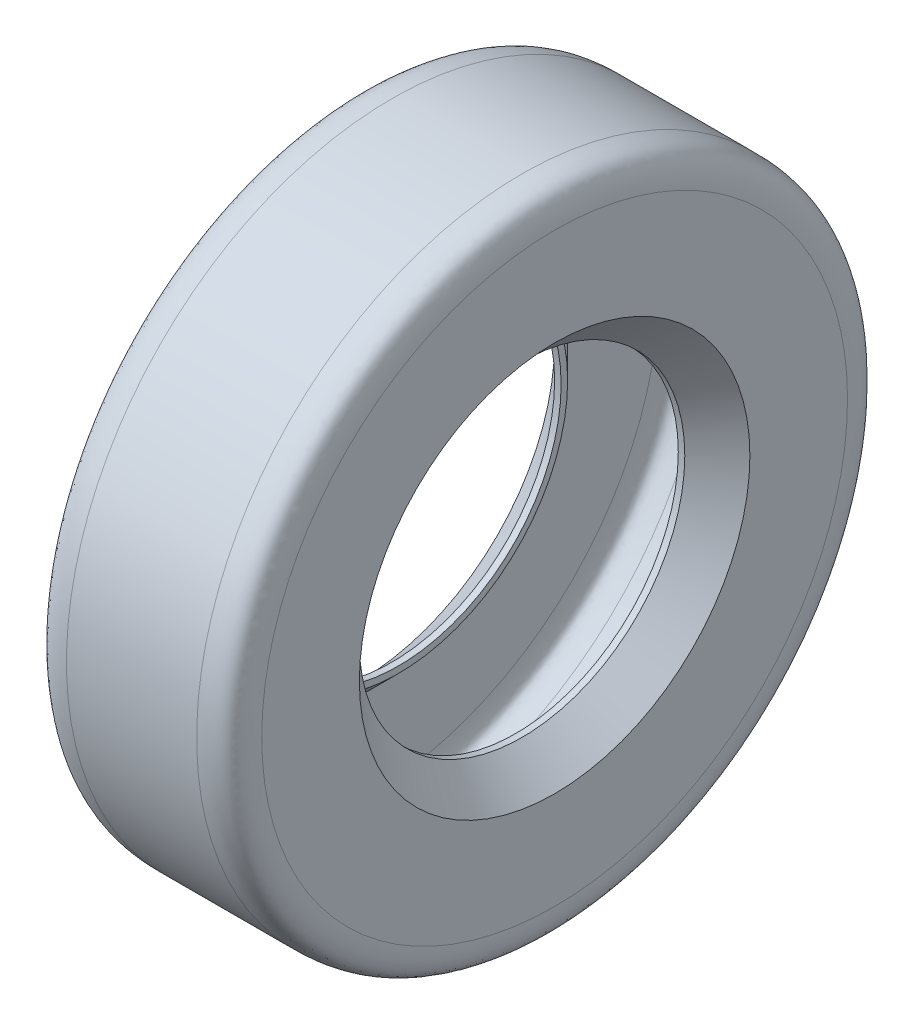
from build123d import *


with BuildPart() as part:
    # Sketch2 → Revolve4 (revolve)
    with BuildSketch(Plane.XY):
        with BuildLine():
            Line((-25.4, 127), (25.4, 127))
            add(Edge.make_bspline(
                [(38.1, 114.3), (38.1, 116.276431222), (38.064423316, 127.022398823), (28.686368964, 127), (25.4, 127)],
                knots=[0, 0, 0, 0, 0.479280716, 1, 1, 1, 1], degree=3))
            Line((38.1, 114.3), (38.1, 76.2))
            Line((38.1, 76.2), (25.4, 63.5))
            Line((25.4, 63.5), (22.86, 63.5))
            Line((22.86, 63.5), (22.86, 66.04))
            Line((22.86, 66.04), (35.56, 78.74))
            Line((35.56, 78.74), (35.56, 114.3))
            add(Edge.make_bspline(
                [(35.56, 114.3), (35.56, 114.437804617), (35.559848134, 114.69919797), (35.554529075, 115.335705853), (35.530423845, 116.249768154), (35.448501321, 117.490904626), (35.291134285, 118.78768894), (35.040001719, 120.054632818), (34.691360923, 121.193385659), (34.249332566, 122.117984468), (33.807571329, 122.705830521), (33.23403142, 123.186604386), (32.200420459, 123.75056219), (30.417055007, 124.242459368), (28.301224859, 124.423710764), (26.605403529, 124.46019646), (25.805832113, 124.46), (25.4, 124.46)],
                knots=[0, 0, 0, 0, 0.03125, 0.0625, 0.125, 0.1875, 0.25, 0.3125, 0.375, 0.4375, 0.5, 0.5625, 0.625, 0.75, 0.875, 0.9375, 1, 1, 1, 1], degree=3))
            Line((25.4, 124.46), (-25.4, 124.46))
            add(Edge.make_bspline(
                [(-35.56, 114.3), (-35.56, 114.437804617), (-35.559848134, 114.69919797), (-35.554529075, 115.335705853), (-35.530423845, 116.249768154), (-35.448501321, 117.490904626), (-35.291134285, 118.78768894), (-35.040001719, 120.054632818), (-34.691360923, 121.193385659), (-34.249332566, 122.117984468), (-33.807571329, 122.705830521), (-33.23403142, 123.186604386), (-32.200420459, 123.75056219), (-30.417055007, 124.242459368), (-28.301224859, 124.423710764), (-26.605403529, 124.46019646), (-25.805832113, 124.46), (-25.4, 124.46)],
                knots=[0, 0, 0, 0, 0.03125, 0.0625, 0.125, 0.1875, 0.25, 0.3125, 0.375, 0.4375, 0.5, 0.5625, 0.625, 0.75, 0.875, 0.9375, 1, 1, 1, 1], degree=3))
            Line((-35.56, 114.3), (-35.56, 78.74))
            Line((-35.56, 78.74), (-22.86, 66.04))
            Line((-22.86, 66.04), (-22.86, 63.5))
            Line((-22.86, 63.5), (-25.4, 63.5))
            Line((-25.4, 63.5), (-38.1, 76.2))
            Line((-38.1, 76.2), (-38.1, 114.3))
            add(Edge.make_bspline(
                [(-38.1, 114.3), (-38.1, 116.276431222), (-38.064423316, 127.022398823), (-28.686368964, 127), (-25.4, 127)],
                knots=[0, 0, 0, 0, 0.479280716, 1, 1, 1, 1], degree=3))
        make_face()
    revolve(axis=Axis((0, 0, 0), (-1, 0, 0)))


solid = part.part
